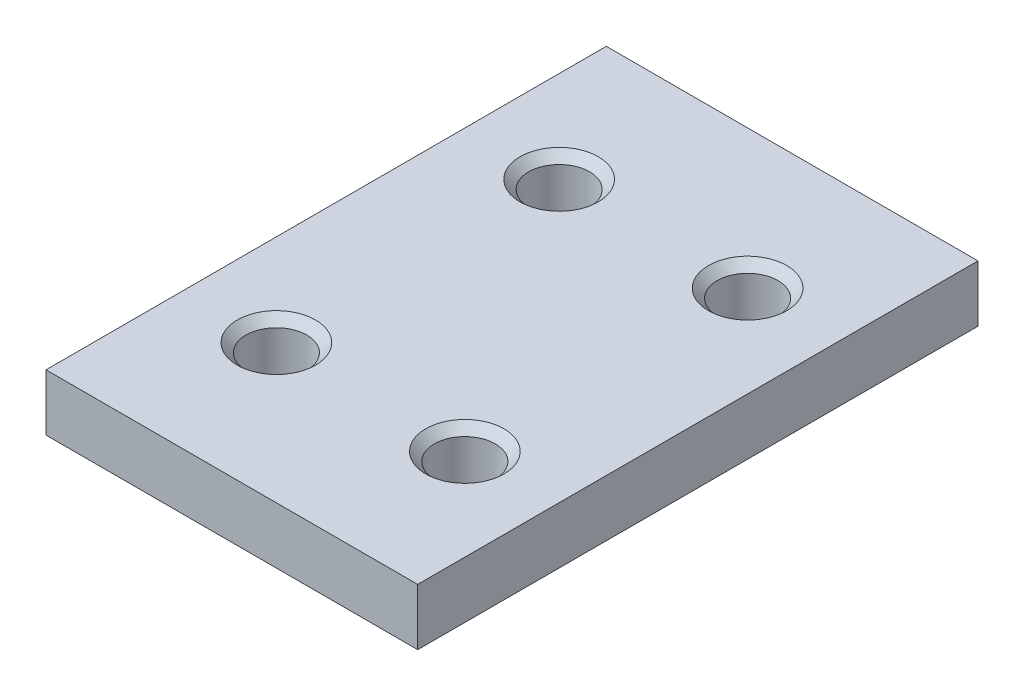
from build123d import *

# Parameters (mm, degrees)
SKETCH1_W           = 42.7202667
SKETCH1_H           = 64.4
BOSS_EXTRUDE1_DEPTH = 6.5
SKETCH2_R           = 3.5
CUT_EXTRUDE1_DEPTH  = 7.5
CHAMFER1_SIZE       = 1


with BuildPart() as part:
    # Sketch1 → Boss-Extrude1 (new body)
    with BuildSketch(Plane(origin=(0, 0, 0), x_dir=(1, 0, 0), z_dir=(0, 1, 0))):
        with Locations((-21.36013335, -32.2)):
            Rectangle(SKETCH1_W, SKETCH1_H)
    extrude(amount=BOSS_EXTRUDE1_DEPTH)

    # Sketch2 → Cut-Extrude1 (cut, through all)
    with BuildSketch(Plane(origin=(0, 6.5, 0), x_dir=(1, 0, 0), z_dir=(0, 1, 0))):
        with BuildLine():
            ThreePointArc((-35.690200025, -15.95), (-32.190200025, -19.45), (-28.690200025, -15.95))
            Line((-28.690200025, -15.95), (-35.690200025, -15.95))
        make_face()
        with BuildLine():
            Line((-35.690200025, -15.95), (-28.690200025, -15.95))
            ThreePointArc((-28.690200025, -15.95), (-32.190200025, -12.45), (-35.690200025, -15.95))
        make_face()
        with BuildLine():
            ThreePointArc((-7.030066675, -15.95), (-8.055192941, -13.475126266), (-10.530066675, -12.45))
            Line((-10.530066675, -12.45), (-10.530066675, -15.95))
            Line((-10.530066675, -15.95), (-7.030066675, -15.95))
        make_face()
        with BuildLine():
            Line((-10.530066675, -15.95), (-10.530066675, -12.45))
            ThreePointArc((-10.530066675, -12.45), (-13.004940409, -13.475126266), (-14.030066675, -15.95))
            Line((-14.030066675, -15.95), (-10.530066675, -15.95))
        make_face()
        with BuildLine():
            Line((-7.030066675, -15.95), (-10.530066675, -15.95))
            Line((-10.530066675, -15.95), (-10.530066675, -19.45))
            ThreePointArc((-10.530066675, -19.45), (-8.055192941, -18.424873734), (-7.030066675, -15.95))
        make_face()
        with BuildLine():
            Line((-10.530066675, -19.45), (-10.530066675, -15.95))
            Line((-10.530066675, -15.95), (-14.030066675, -15.95))
            ThreePointArc((-14.030066675, -15.95), (-13.004940409, -18.424873734), (-10.530066675, -19.45))
        make_face()
        with Locations((-32.190200025, -48.45)):
            Circle(SKETCH2_R)
        with BuildLine():
            ThreePointArc((-7.030066675, -48.45), (-8.055192941, -45.975126266), (-10.530066675, -44.95))
            Line((-10.530066675, -44.95), (-10.530066675, -51.95))
            ThreePointArc((-10.530066675, -51.95), (-8.055192941, -50.924873734), (-7.030066675, -48.45))
        make_face()
        with BuildLine():
            Line((-10.530066675, -51.95), (-10.530066675, -44.95))
            ThreePointArc((-10.530066675, -44.95), (-14.030066675, -48.45), (-10.530066675, -51.95))
        make_face()
    extrude(amount=-CUT_EXTRUDE1_DEPTH, mode=Mode.SUBTRACT)

    # Chamfer1
    chamfer1_edges = [part.edges().sort_by_distance(p)[0] for p in [
        (-10.530066675, 6.5, 44.95),
        (-35.690200025, 6.5, 48.45),
        (-28.690200025, 6.5, 15.95),
        (-10.530066675, 6.5, 12.45),
    ]]
    chamfer(chamfer1_edges, length=CHAMFER1_SIZE)


solid = part.part
